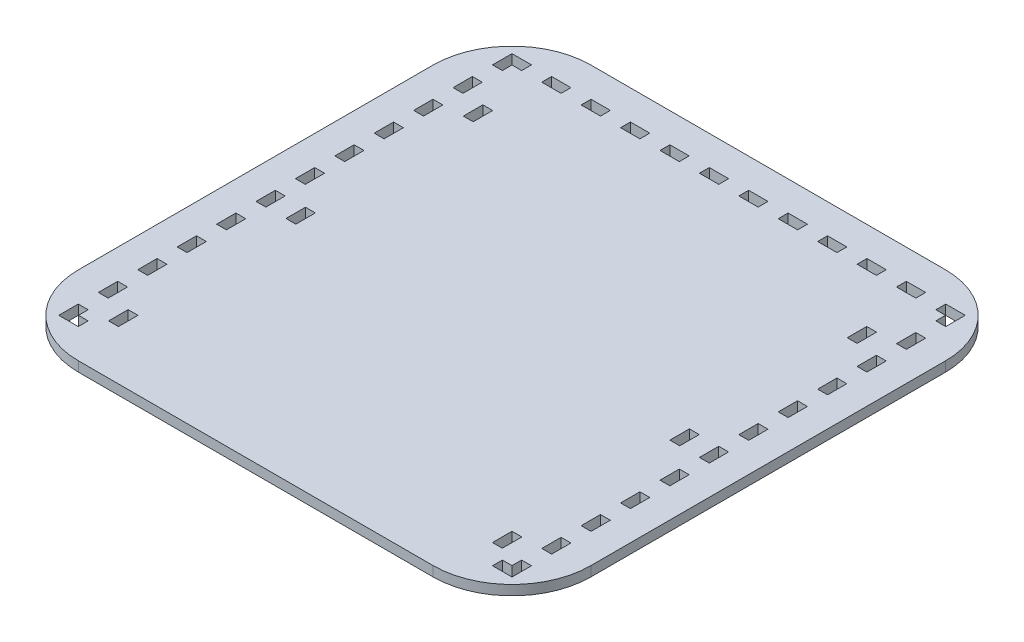
from build123d import *

# Parameters (mm, degrees)
SKETCH1_W           = 6.35
SKETCH1_H           = 12.446
SKETCH1_W_2         = 12.446
SKETCH1_H_2         = 6.35
SKETCH1_H_3         = 12.573
BOSS_EXTRUDE1_DEPTH = 6.35


with BuildPart() as part:
    # Sketch1 → Boss-Extrude1 (new body)
    with BuildSketch(Plane(origin=(0, 0, 0), x_dir=(1, 0, 0), z_dir=(0, 1, 0))):
        with BuildLine():
            Line((19.177, -311.15), (247.777, -311.15))
            ThreePointArc((247.777, -311.15), (283.698024484, -296.271024484), (298.577, -260.35))
            Line((298.577, -260.35), (298.577, -31.75))
            ThreePointArc((298.577, -31.75), (283.698024484, 4.171024484), (247.777, 19.05))
            Line((247.777, 19.05), (19.177, 19.05))
            ThreePointArc((19.177, 19.05), (-16.744024484, 4.171024484), (-31.623, -31.75))
            Line((-31.623, -31.75), (-31.623, -260.35))
            ThreePointArc((-31.623, -260.35), (-16.744024484, -296.271024484), (19.177, -311.15))
        make_face()
        with Locations((-9.398, -234.95)):
            Rectangle(SKETCH1_W, SKETCH1_H, mode=Mode.SUBTRACT)
        with Locations((-9.398, -209.55)):
            Rectangle(SKETCH1_W, SKETCH1_H, mode=Mode.SUBTRACT)
        with Locations((-9.398, -184.15)):
            Rectangle(SKETCH1_W, SKETCH1_H, mode=Mode.SUBTRACT)
        with Locations((-9.398, -158.75)):
            Rectangle(SKETCH1_W, SKETCH1_H, mode=Mode.SUBTRACT)
        with Locations((-9.398, -133.35)):
            Rectangle(SKETCH1_W, SKETCH1_H, mode=Mode.SUBTRACT)
        with Locations((-9.398, -107.95)):
            Rectangle(SKETCH1_W, SKETCH1_H, mode=Mode.SUBTRACT)
        with Locations((-9.398, -82.55)):
            Rectangle(SKETCH1_W, SKETCH1_H, mode=Mode.SUBTRACT)
        with Locations((-9.398, -57.15)):
            Rectangle(SKETCH1_W, SKETCH1_H, mode=Mode.SUBTRACT)
        with Locations((-9.398, -31.75)):
            Rectangle(SKETCH1_W, SKETCH1_H, mode=Mode.SUBTRACT)
        Polygon((-6.223, -12.573), (-12.573, -12.573), (-12.573, 0), (0, 0), (0, -6.35), (-6.223, -6.35), align=None, mode=Mode.SUBTRACT)
        Polygon((273.177, -285.75), (273.177, -279.527), (279.527, -279.527), (279.527, -292.1), (266.954, -292.1), (266.954, -285.75), align=None, mode=Mode.SUBTRACT)
        with Locations((276.352, -260.35)):
            Rectangle(SKETCH1_W, SKETCH1_H, mode=Mode.SUBTRACT)
        with Locations((276.352, -234.95)):
            Rectangle(SKETCH1_W, SKETCH1_H, mode=Mode.SUBTRACT)
        Polygon((-6.223, -279.527), (-6.223, -285.75), (0, -285.75), (0, -292.1), (-12.573, -292.1), (-12.573, -279.527), align=None, mode=Mode.SUBTRACT)
        with Locations((-9.398, -260.35)):
            Rectangle(SKETCH1_W, SKETCH1_H, mode=Mode.SUBTRACT)
        with Locations((276.352, -209.55)):
            Rectangle(SKETCH1_W, SKETCH1_H, mode=Mode.SUBTRACT)
        with Locations((276.352, -184.15)):
            Rectangle(SKETCH1_W, SKETCH1_H, mode=Mode.SUBTRACT)
        with Locations((276.352, -158.75)):
            Rectangle(SKETCH1_W, SKETCH1_H, mode=Mode.SUBTRACT)
        with Locations((276.352, -133.35)):
            Rectangle(SKETCH1_W, SKETCH1_H, mode=Mode.SUBTRACT)
        with Locations((276.352, -107.95)):
            Rectangle(SKETCH1_W, SKETCH1_H, mode=Mode.SUBTRACT)
        with Locations((276.352, -82.55)):
            Rectangle(SKETCH1_W, SKETCH1_H, mode=Mode.SUBTRACT)
        with Locations((276.352, -57.15)):
            Rectangle(SKETCH1_W, SKETCH1_H, mode=Mode.SUBTRACT)
        with Locations((276.352, -31.75)):
            Rectangle(SKETCH1_W, SKETCH1_H, mode=Mode.SUBTRACT)
        Polygon((279.527, -12.573), (273.177, -12.573), (273.177, -6.35), (266.954, -6.35), (266.954, 0), (279.527, 0), align=None, mode=Mode.SUBTRACT)
        with Locations((19.177, -3.175)):
            Rectangle(SKETCH1_W_2, SKETCH1_H_2, mode=Mode.SUBTRACT)
        with Locations((44.577, -3.175)):
            Rectangle(SKETCH1_W_2, SKETCH1_H_2, mode=Mode.SUBTRACT)
        with Locations((69.977, -3.175)):
            Rectangle(SKETCH1_W_2, SKETCH1_H_2, mode=Mode.SUBTRACT)
        with Locations((95.377, -3.175)):
            Rectangle(SKETCH1_W_2, SKETCH1_H_2, mode=Mode.SUBTRACT)
        with Locations((120.777, -3.175)):
            Rectangle(SKETCH1_W_2, SKETCH1_H_2, mode=Mode.SUBTRACT)
        with Locations((146.177, -3.175)):
            Rectangle(SKETCH1_W_2, SKETCH1_H_2, mode=Mode.SUBTRACT)
        with Locations((171.577, -3.175)):
            Rectangle(SKETCH1_W_2, SKETCH1_H_2, mode=Mode.SUBTRACT)
        with Locations((196.977, -3.175)):
            Rectangle(SKETCH1_W_2, SKETCH1_H_2, mode=Mode.SUBTRACT)
        with Locations((222.377, -3.175)):
            Rectangle(SKETCH1_W_2, SKETCH1_H_2, mode=Mode.SUBTRACT)
        with Locations((247.777, -3.175)):
            Rectangle(SKETCH1_W_2, SKETCH1_H_2, mode=Mode.SUBTRACT)
        with Locations((257.175, -158.5595)):
            Rectangle(SKETCH1_W, SKETCH1_H_3, mode=Mode.SUBTRACT)
        with Locations((257.175, -272.8595)):
            Rectangle(SKETCH1_W, SKETCH1_H_3, mode=Mode.SUBTRACT)
        with Locations((257.175, -44.2595)):
            Rectangle(SKETCH1_W, SKETCH1_H_3, mode=Mode.SUBTRACT)
        with Locations((9.779, -44.2595)):
            Rectangle(SKETCH1_W, SKETCH1_H_3, mode=Mode.SUBTRACT)
        with Locations((9.779, -158.5595)):
            Rectangle(SKETCH1_W, SKETCH1_H_3, mode=Mode.SUBTRACT)
        with Locations((9.779, -272.8595)):
            Rectangle(SKETCH1_W, SKETCH1_H_3, mode=Mode.SUBTRACT)
    extrude(amount=BOSS_EXTRUDE1_DEPTH)


solid = part.part
